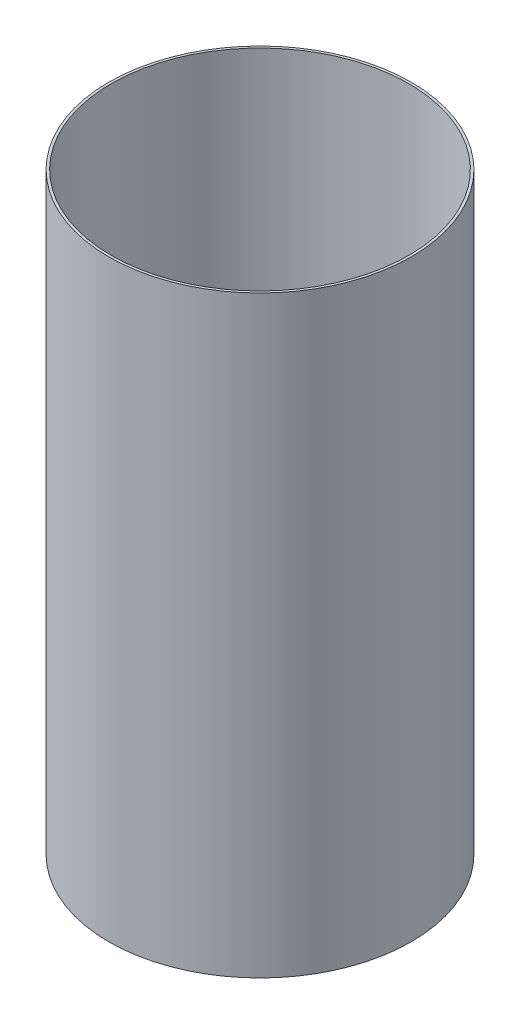
from build123d import *

# Parameters (mm, degrees)
SKETCH1_R           = 77.724
SKETCH1_R_2         = 76.454
EXTRUDE_THIN2_DEPTH = 304.8
SKETCH3_R           = 3.302
CUT_EXTRUDE2_DEPTH  = 2.54
CIRPATTERN2_COUNT   = 3


with BuildPart() as part:
    # Sketch1 → Extrude-Thin2 (new body)
    with BuildSketch(Plane(origin=(0, 0, 0), x_dir=(1, 0, 0), z_dir=(0, 1, 0))):
        Circle(SKETCH1_R)
        Circle(SKETCH1_R_2, mode=Mode.SUBTRACT)
    extrude(amount=EXTRUDE_THIN2_DEPTH)

    # Sketch3 → Cut-Extrude2 (cut)
    with BuildSketch(Plane.ZY.offset(-76.454)):
        with Locations((0, 63.5)):
            Circle(SKETCH3_R)
    cut_extrude2 = extrude(amount=CUT_EXTRUDE2_DEPTH, mode=Mode.SUBTRACT)

    # CirPattern2: Cut-Extrude2 ×3 about axis
    cirpattern2_axis = Axis((0, 0, 0), (0, 1, 0))
    for i in range(1, CIRPATTERN2_COUNT):
        add(cut_extrude2.rotate(cirpattern2_axis, i * 360 / CIRPATTERN2_COUNT), mode=Mode.SUBTRACT)


solid = part.part
